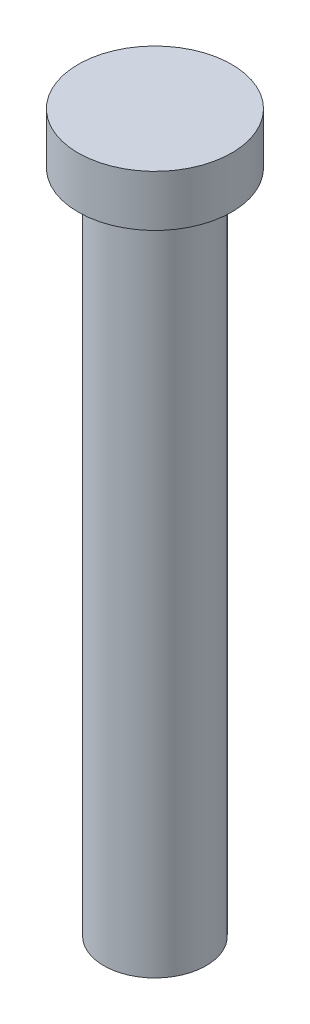
from build123d import *

# Parameters (mm, degrees)
SKETCH1_R           = 1.905
BOSS_EXTRUDE1_DEPTH = 1.27
SKETCH2_R           = 1.27
BOSS_EXTRUDE2_DEPTH = 16.51


with BuildPart() as part:
    # Sketch1 → Boss-Extrude1 (new body)
    with BuildSketch(Plane(origin=(0, 0, 0), x_dir=(1, 0, 0), z_dir=(0, 1, 0))):
        Circle(SKETCH1_R)
    extrude(amount=BOSS_EXTRUDE1_DEPTH)

    # Sketch2 → Boss-Extrude2 (add)
    with BuildSketch(Plane.XZ):
        Circle(SKETCH2_R)
    extrude(amount=BOSS_EXTRUDE2_DEPTH)


solid = part.part
